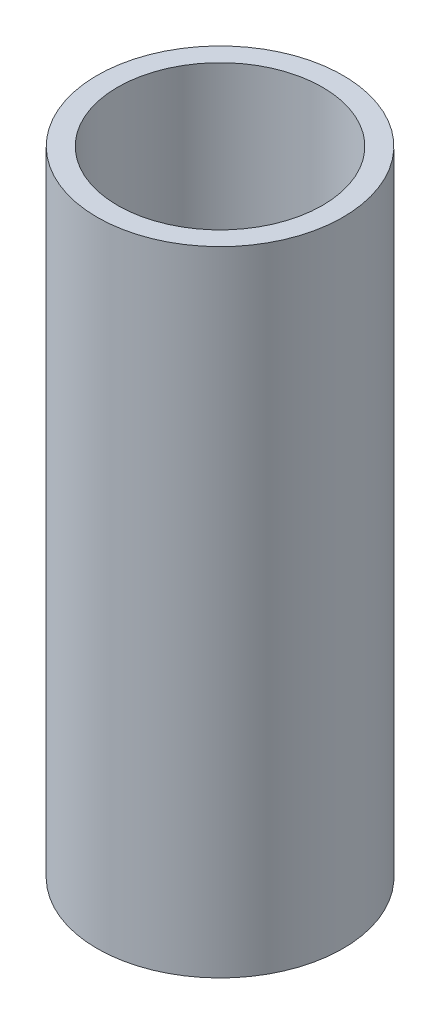
from build123d import *

# Parameters (mm, degrees)
SKETCH1_R           = 1.95
SKETCH1_R_2         = 1.625
BOSS_EXTRUDE1_DEPTH = 5.024


with BuildPart() as part:
    # Sketch1 → Boss-Extrude1 (new body, symmetric)
    with BuildSketch(Plane(origin=(0, 0, 0), x_dir=(1, 0, 0), z_dir=(0, 1, 0))):
        Circle(SKETCH1_R)
        Circle(SKETCH1_R_2, mode=Mode.SUBTRACT)
    extrude(amount=BOSS_EXTRUDE1_DEPTH, both=True)


solid = part.part
